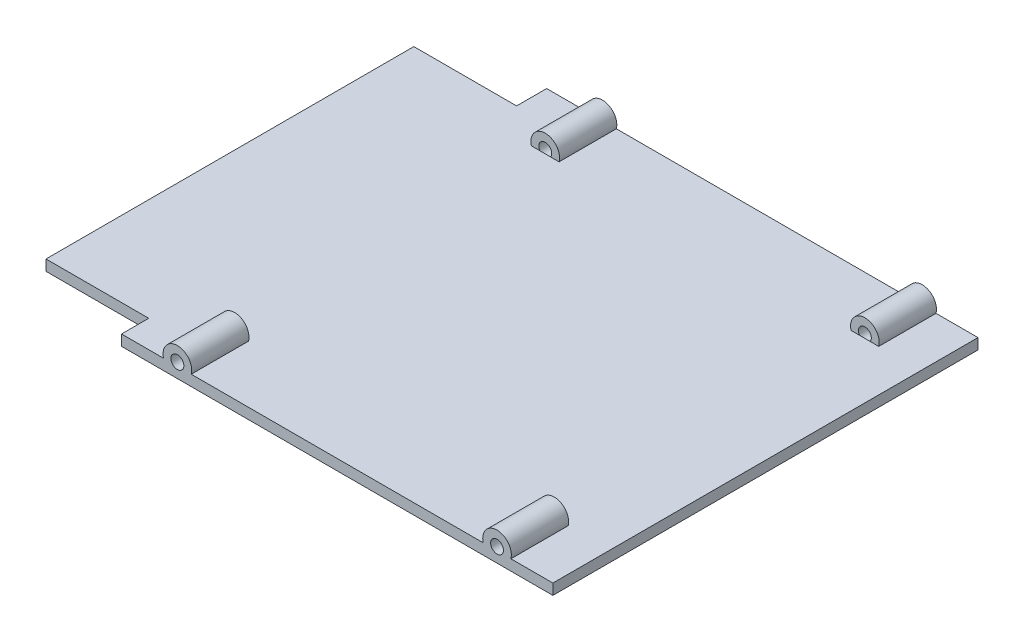
from build123d import *

# Parameters (mm, degrees)
BOSS_EXTRUDE1_START = -14.587445
SKETCH1_W           = 60.25
SKETCH1_H           = 1.5
BOSS_EXTRUDE1_DEPTH = 59.38
SKETCH2_W           = 51.38
SKETCH2_H           = 1.5
BOSS_EXTRUDE2_DEPTH = 14.35
SKETCH3_R           = 1.999999999
SKETCH3_R_2         = 2.000000001
BOSS_EXTRUDE3_DEPTH = 8
SKETCH4_R           = 0.9
CUT_EXTRUDE1_DEPTH  = 8
SKETCH5_R           = 2
BOSS_EXTRUDE4_DEPTH = 8
SKETCH6_R           = 0.9
CUT_EXTRUDE2_DEPTH  = 8


with BuildPart() as part:
    # Sketch1 → Boss-Extrude1 (new body)
    with BuildSketch(Plane.XY.offset(BOSS_EXTRUDE1_START)):
        with Locations((-537.019993097, -25.517194875)):
            Rectangle(SKETCH1_W, SKETCH1_H)
    extrude(amount=BOSS_EXTRUDE1_DEPTH)

    # Sketch2 → Boss-Extrude2 (add)
    with BuildSketch(Plane.ZY.offset(567.144993097)):
        with Locations((15.302555296, -25.517194875)):
            Rectangle(SKETCH2_W, SKETCH2_H)
    extrude(amount=BOSS_EXTRUDE2_DEPTH)

    # Sketch3 → Boss-Extrude3 (add)
    with BuildSketch(Plane(origin=(0, 0, -14.587444704), x_dir=(-1, 0, 0), z_dir=(0, 0, -1))):
        with Locations((559.344993097, -24.267194875)):
            Circle(SKETCH3_R)
        with Locations((514.694993097, -24.267194875)):
            Circle(SKETCH3_R_2)
    extrude(amount=-BOSS_EXTRUDE3_DEPTH)

    # Sketch4 → Cut-Extrude1 (cut)
    with BuildSketch(Plane(origin=(0, 0, -14.587444704), x_dir=(-1, 0, 0), z_dir=(0, 0, -1))):
        with Locations((559.344993097, -24.267194875)):
            Circle(SKETCH4_R)
        with Locations((514.694993097, -24.267194875)):
            Circle(SKETCH4_R)
    extrude(amount=-CUT_EXTRUDE1_DEPTH, mode=Mode.SUBTRACT)

    # Sketch5 → Boss-Extrude4 (add)
    with BuildSketch(Plane.XY.offset(44.792555296)):
        with Locations((-559.344993097, -24.267194875)):
            Circle(SKETCH5_R)
        with Locations((-514.694993097, -24.267194875)):
            Circle(SKETCH5_R)
    extrude(amount=-BOSS_EXTRUDE4_DEPTH)

    # Sketch6 → Cut-Extrude2 (cut)
    with BuildSketch(Plane.XY.offset(44.792555296)):
        with Locations((-514.694993097, -24.267194875)):
            Circle(SKETCH6_R)
        with Locations((-559.344993097, -24.267194875)):
            Circle(SKETCH6_R)
    extrude(amount=-CUT_EXTRUDE2_DEPTH, mode=Mode.SUBTRACT)


solid = part.part
